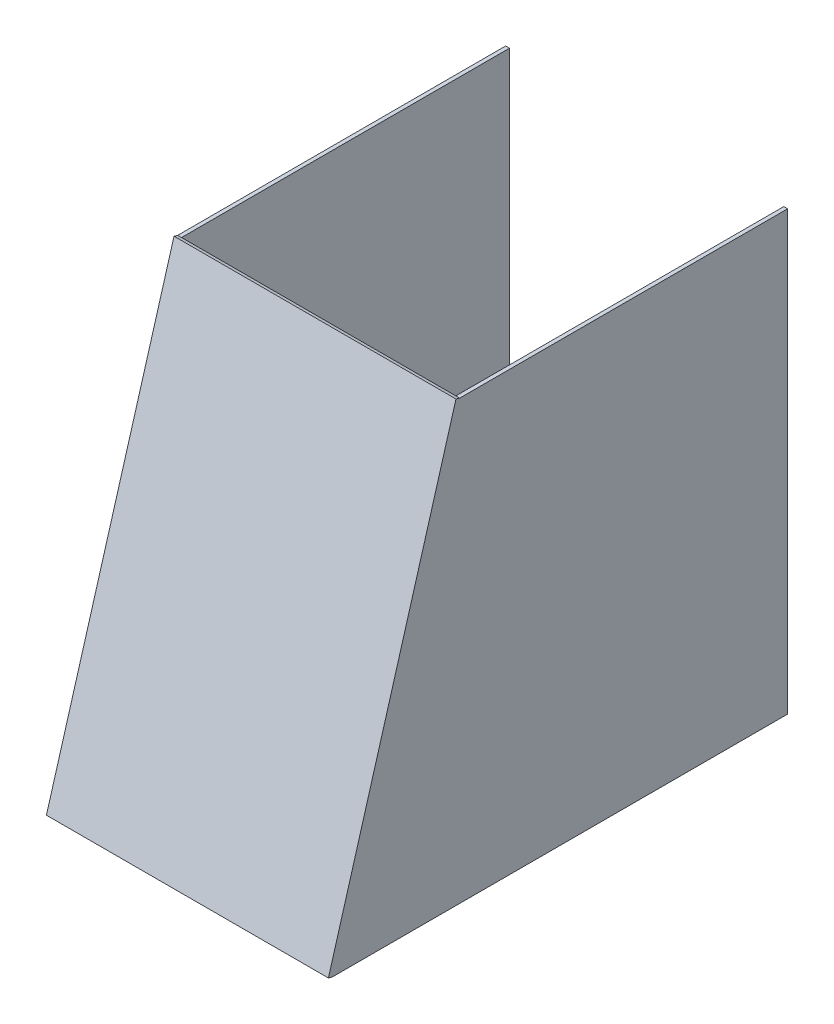
from build123d import *

# Parameters (mm, degrees)
BOSS_EXTRUDE1_DEPTH = 3
SKETCH2_W           = 221
SKETCH2_H           = 357.28000224
BOSS_EXTRUDE2_DEPTH = 3


with BuildPart() as part:
    # Sketch1 → Boss-Extrude1 (new body)
    with BuildSketch(Plane(origin=(107.5, 0, 0), x_dir=(0, 0, -1), z_dir=(1, 0, 0))):
        Polygon((125.5, 330), (-131.5, 330), (-231.5, -13), (125.5, -13), align=None)
    extrude(amount=BOSS_EXTRUDE1_DEPTH)


with BuildPart() as body_2:
    # Mirror2: mirrored copy
    add(part.part.mirror(Plane(origin=(0, 0, 0), x_dir=(0, 0, 1), z_dir=(1, 0, 0))))


with BuildPart() as part_1:
    add(part.part)

    add(body_2.part)  # Boss-Extrude2 merges body 2
    # Sketch2 → Boss-Extrude2 (add)
    with BuildSketch(Plane(origin=(0, 61.18692665, 209.871158411), x_dir=(1, 0, 0), z_dir=(0, 0.27989252, 0.960031342))):
        with Locations((0, 101.364475406)):
            Rectangle(SKETCH2_W, SKETCH2_H)
    extrude(amount=BOSS_EXTRUDE2_DEPTH)


solid = part_1.part
